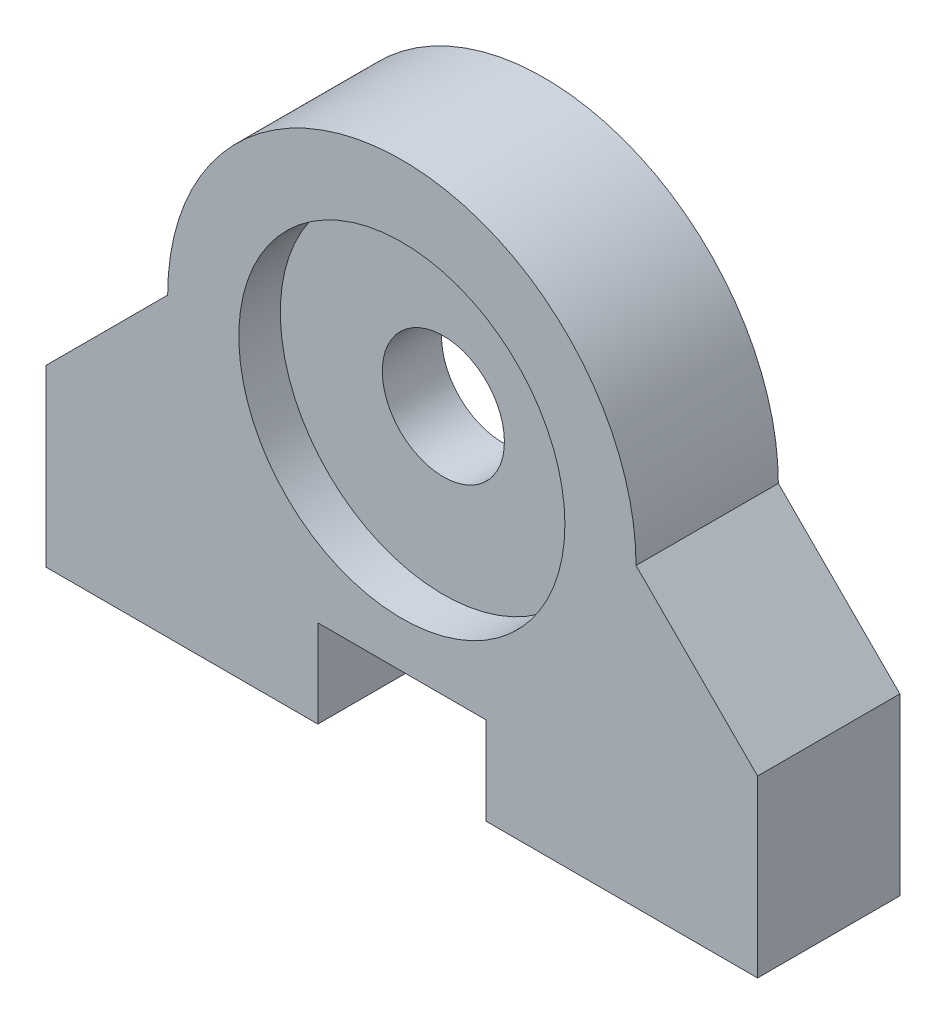
from build123d import *

# Parameters (mm, degrees)
SKETCH1_R                = 8.73125
BOSS_EXTRUDE1_DEPTH      = 7.62
SKETCH3_R                = 8.7376
SKETCH3_R_2              = 3.27025
BOSS_EXTRUDE2_DEPTH      = 1.5875
BOSS_EXTRUDE2_DEPTH_BACK = 1.5875
SKETCH4_R                = 1.98374
CUT_EXTRUDE1_DEPTH       = 10.16


with BuildPart() as part:
    # Sketch1 → Boss-Extrude1 (new body)
    with BuildSketch(Plane.XY):
        with BuildLine():
            Line((4.5, 4.699), (-4.5, 4.699))
            Line((-4.5, 4.699), (-4.5, 0))
            Line((-4.5, 0), (-19.05, 0))
            Line((-19.05, 0), (-19.05, 9.36625))
            Line((-19.05, 9.36625), (-12.54125, 15.875))
            ThreePointArc((-12.54125, 15.875), (0, 28.41625), (12.54125, 15.875))
            Line((12.54125, 15.875), (19.05, 9.36625))
            Line((19.05, 9.36625), (19.05, 0))
            Line((19.05, 0), (4.5, 0))
            Line((4.5, 0), (4.5, 4.699))
        make_face()
        with Locations((0, 15.875)):
            Circle(SKETCH1_R, mode=Mode.SUBTRACT)
    extrude(amount=BOSS_EXTRUDE1_DEPTH)

    # Sketch3 → Boss-Extrude2 (add, two sides)
    with BuildSketch(Plane.XY.offset(3.81)) as boss_extrude2_sk:
        with Locations((0, 15.875)):
            Circle(SKETCH3_R)
        with Locations((0, 15.875)):
            Circle(SKETCH3_R_2, mode=Mode.SUBTRACT)
    extrude(amount=BOSS_EXTRUDE2_DEPTH)
    extrude(boss_extrude2_sk.sketch, amount=-BOSS_EXTRUDE2_DEPTH_BACK)

    # Sketch4 → Cut-Extrude1 (cut)
    with BuildSketch(Plane(origin=(0, 0, 0), x_dir=(-1, 0, 0), z_dir=(0, -1, 0))):
        with Locations((-11.43, -3.81)):
            Circle(SKETCH4_R)
        with Locations((11.43, -3.81)):
            Circle(SKETCH4_R)
    extrude(amount=-CUT_EXTRUDE1_DEPTH, mode=Mode.SUBTRACT)


solid = part.part
